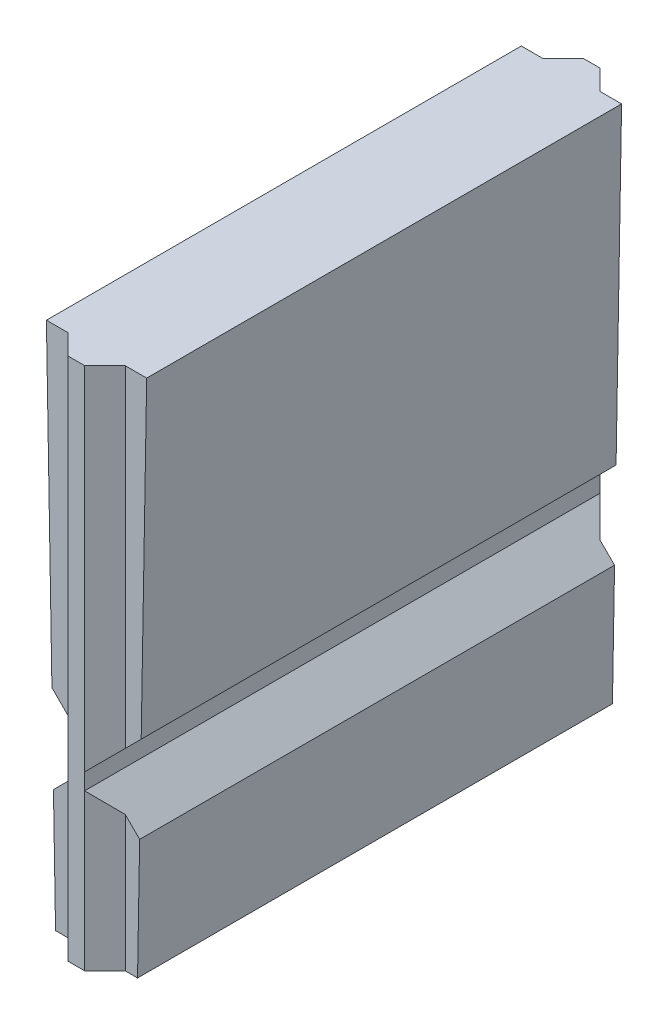
from build123d import *

# Parameters (mm, degrees)
BOSS_EXTRUDE1_DEPTH = 13.2334
BOSS_EXTRUDE2_DEPTH = 14.605
CUT_EXTRUDE1_DEPTH  = 14.36116


with BuildPart() as part:
    # Sketch1 → Boss-Extrude1 (new body)
    with BuildSketch(Plane.XY):
        Polygon((-1.142068777, 0), (1.142068777, 0), (1.397, 14.605), (-1.397, 14.605), align=None)
    extrude(amount=BOSS_EXTRUDE1_DEPTH)

    # Sketch2 → Boss-Extrude2 (add)
    with BuildSketch(Plane.XZ):
        Polygon((-0.8001, 13.2334), (0.8001, 13.2334), (0.23114, 13.79728), (-0.23368, 13.79728), align=None)
    boss_extrude2 = extrude(amount=-BOSS_EXTRUDE2_DEPTH)

    # Mirror1: Boss-Extrude2 across plane
    add(boss_extrude2.mirror(Plane.XY.offset(6.6167)))

    # Sketch3 → Cut-Extrude1 (cut)
    with BuildSketch(Plane.XY.offset(13.79728)):
        Polygon((-1.243534982, 5.812994982), (-0.23368, 4.8006), (-0.23368, 4.3434), (-1.200976725, 3.374834107), align=None)
        Polygon((1.243534982, 5.812994982), (0.23114, 4.8006), (0.23114, 4.3434), (1.200976725, 3.374834107), align=None)
    extrude(amount=-CUT_EXTRUDE1_DEPTH, mode=Mode.SUBTRACT)


solid = part.part
